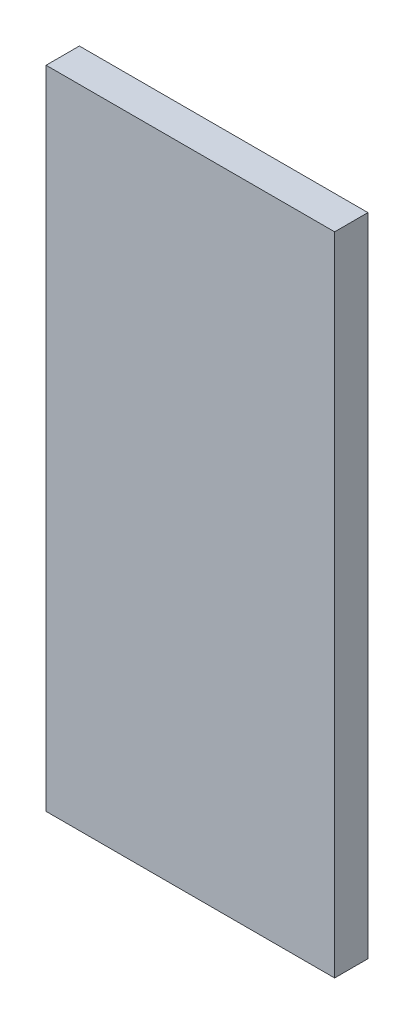
from build123d import *

# Parameters (mm, degrees)
SKETCH1_W           = 86.683733235
SKETCH1_H           = 194.138919348
BOSS_EXTRUDE2_DEPTH = 10


with BuildPart() as part:
    # Sketch1 → Boss-Extrude2 (new body)
    with BuildSketch(Plane.XY):
        with Locations((20.599224535, -84.069459674)):
            Rectangle(SKETCH1_W, SKETCH1_H)
    extrude(amount=BOSS_EXTRUDE2_DEPTH)


solid = part.part
